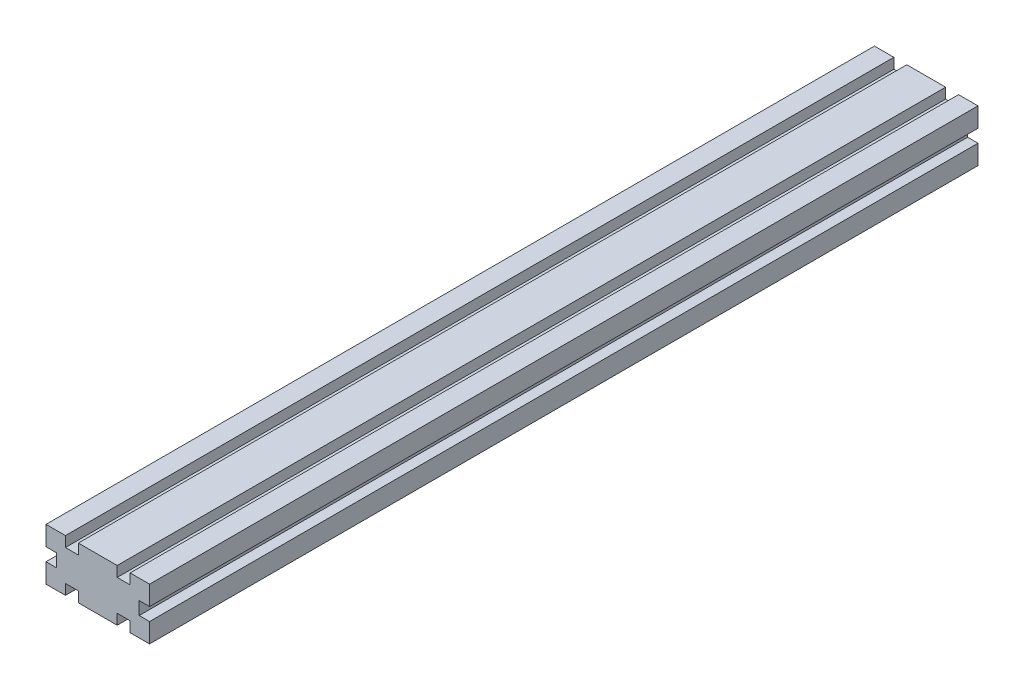
from build123d import *

# Parameters (mm, degrees)
ESQUISSE1_W        = 3.5
ESQUISSE1_H        = 5
ESQUISSE1_W_2      = 5
ESQUISSE1_H_2      = 3.5
ESQUISSE1_W_3      = 4
BOSS_EXTRU_1_DEPTH = 320


with BuildPart() as part:
    # Esquisse1 → Boss.-Extru.1 (new body)
    with BuildSketch(Plane.XY):
        Polygon((7.5, 16), (7.5, 20), (0, 20), (4, 16), align=None)
        Polygon((4, 16), (0, 20), (0, 12.5), (4, 12.5), align=None)
        Polygon((4, 7.5), (0, 7.5), (0, 0), (4, 4), align=None)
        Polygon((0, 0), (7.5, 0), (7.5, 4), (4, 4), align=None)
        Polygon((4, 4), (7.5, 7.5), (4, 7.5), align=None)
        Polygon((7.5, 4), (7.5, 7.5), (4, 4), align=None)
        Polygon((4, 12.5), (7.5, 12.5), (4, 16), align=None)
        Polygon((7.5, 12.5), (7.5, 16), (4, 16), align=None)
        with Locations((5.75, 10)):
            Rectangle(ESQUISSE1_W, ESQUISSE1_H)
        Polygon((7.5, 7.5), (10, 10), (7.5, 12.5), align=None)
        Polygon((10, 10), (12.5, 12.5), (7.5, 12.5), align=None)
        Polygon((12.5, 7.5), (12.5, 12.5), (10, 10), align=None)
        Polygon((12.5, 7.5), (10, 10), (7.5, 7.5), align=None)
        Polygon((16, 4), (12.5, 7.5), (12.5, 4), align=None)
        Polygon((16, 4), (16, 7.5), (12.5, 7.5), align=None)
        Polygon((20, 0), (20, 7.5), (16, 7.5), (16, 4), align=None)
        with Locations((10, 14.25)):
            Rectangle(ESQUISSE1_W_2, ESQUISSE1_H_2)
        with Locations((14.25, 10)):
            Rectangle(ESQUISSE1_W, ESQUISSE1_H)
        Polygon((12.5, 12.5), (16, 16), (12.5, 16), align=None)
        Polygon((16, 16), (20, 20), (12.5, 20), (12.5, 16), align=None)
        Polygon((16, 12.5), (16, 16), (12.5, 12.5), align=None)
        Polygon((20, 12.5), (20, 20), (16, 16), (16, 12.5), align=None)
        Polygon((12.5, 0), (20, 0), (16, 4), (12.5, 4), align=None)
        with Locations((10, 5.75)):
            Rectangle(ESQUISSE1_W_2, ESQUISSE1_H_2)
        with Locations((18, 10)):
            Rectangle(ESQUISSE1_W_3, ESQUISSE1_H)
        with Locations((22, 10)):
            Rectangle(ESQUISSE1_W_3, ESQUISSE1_H)
        Polygon((24, 16), (20, 20), (20, 12.5), (24, 12.5), align=None)
        Polygon((27.5, 20), (20, 20), (24, 16), (27.5, 16), align=None)
        Polygon((27.5, 12.5), (24, 16), (24, 12.5), align=None)
        Polygon((27.5, 16), (24, 16), (27.5, 12.5), align=None)
        with Locations((25.75, 10)):
            Rectangle(ESQUISSE1_W, ESQUISSE1_H)
        Polygon((27.5, 7.5), (24, 7.5), (24, 4), align=None)
        Polygon((24, 7.5), (20, 7.5), (20, 0), (24, 4), align=None)
        Polygon((24, 4), (20, 0), (27.5, 0), (27.5, 4), align=None)
        Polygon((27.5, 4), (27.5, 7.5), (24, 4), align=None)
        with Locations((30, 5.75)):
            Rectangle(ESQUISSE1_W_2, ESQUISSE1_H_2)
        Polygon((36, 4), (32.5, 7.5), (32.5, 4), align=None)
        Polygon((36, 7.5), (32.5, 7.5), (36, 4), align=None)
        Polygon((40, 0), (40, 7.5), (36, 7.5), (36, 4), align=None)
        Polygon((32.5, 4), (32.5, 0), (40, 0), (36, 4), align=None)
        with Locations((34.25, 10)):
            Rectangle(ESQUISSE1_W, ESQUISSE1_H)
        Polygon((32.5, 12.5), (30, 10), (32.5, 7.5), align=None)
        Polygon((32.5, 7.5), (30, 10), (27.5, 7.5), align=None)
        Polygon((30, 10), (27.5, 12.5), (27.5, 7.5), align=None)
        Polygon((32.5, 12.5), (27.5, 12.5), (30, 10), align=None)
        Polygon((36, 16), (32.5, 12.5), (36, 12.5), align=None)
        Polygon((36, 16), (32.5, 16), (32.5, 12.5), align=None)
        Polygon((40, 20), (32.5, 20), (32.5, 16), (36, 16), align=None)
        Polygon((40, 12.5), (40, 20), (36, 16), (36, 12.5), align=None)
        with Locations((30, 14.25)):
            Rectangle(ESQUISSE1_W_2, ESQUISSE1_H_2)
    extrude(amount=BOSS_EXTRU_1_DEPTH)


solid = part.part
